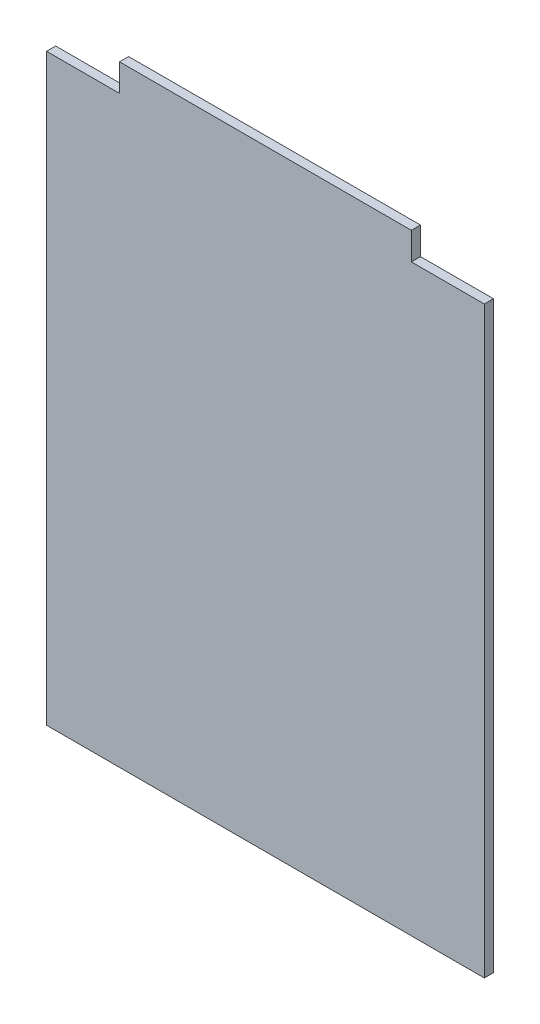
from build123d import *

# Parameters (mm, degrees)
ESQUISSE1_W             = 480
ESQUISSE1_H             = 670
BOSS_EXTRU_1_DEPTH      = 10
ESQUISSE2_W             = 80
ESQUISSE2_H             = 30
ENL_V_MAT_EXTRU_1_DEPTH = 11


with BuildPart() as part:
    # Esquisse1 → Boss.-Extru.1 (new body)
    with BuildSketch(Plane.XY):
        with Locations((-50, 0)):
            Rectangle(ESQUISSE1_W, ESQUISSE1_H)
    extrude(amount=BOSS_EXTRU_1_DEPTH)

    # Esquisse2 → Enlèv. mat.-Extru.1 (cut, through all)
    with BuildSketch(Plane(origin=(0, 0, 0), x_dir=(-1, 0, 0), z_dir=(0, 0, -1))):
        with Locations((-150, 320)):
            Rectangle(ESQUISSE2_W, ESQUISSE2_H)
        with Locations((250, 320)):
            Rectangle(ESQUISSE2_W, ESQUISSE2_H)
    extrude(amount=-ENL_V_MAT_EXTRU_1_DEPTH, mode=Mode.SUBTRACT)


solid = part.part
